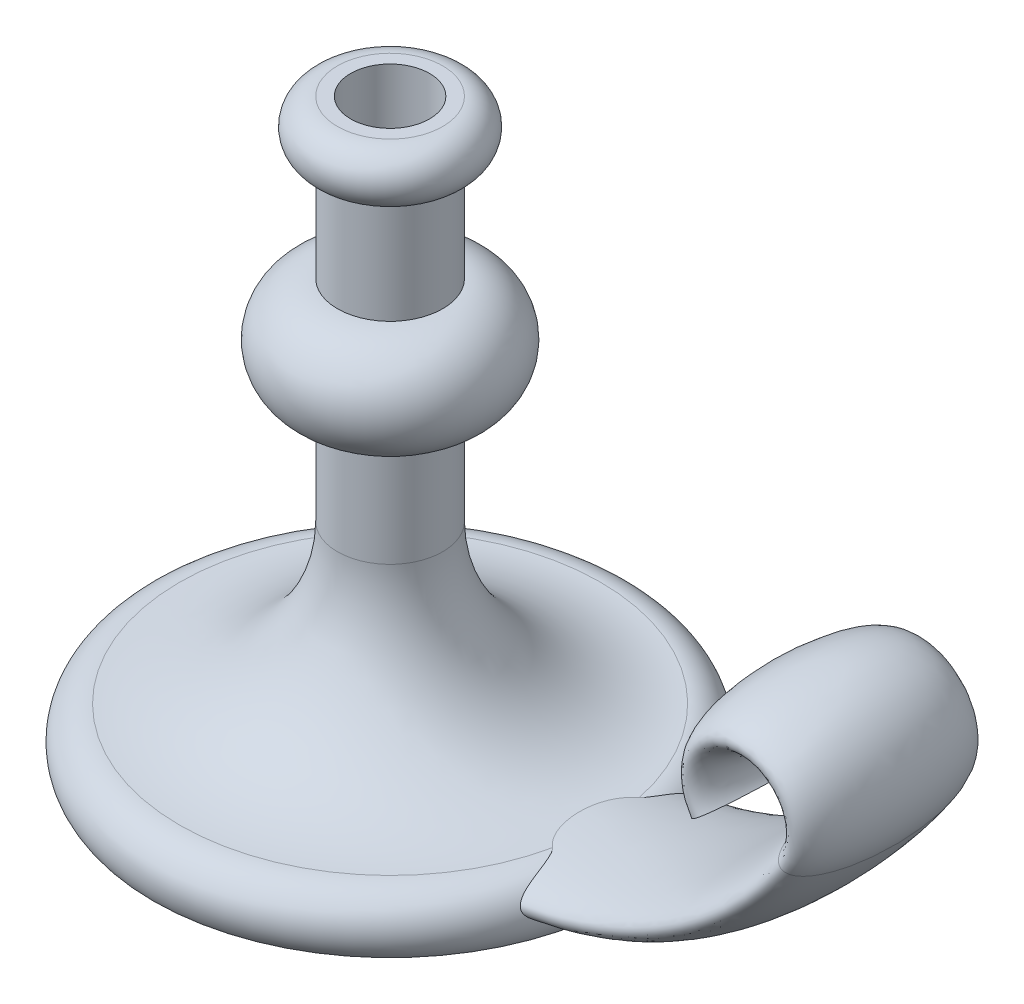
from build123d import *

# Parameters (mm, degrees)
SKETCH3_RX         = 35
SKETCH3_RY         = 10
SKETCH7_R          = 15
CUT_EXTRUDE1_DEPTH = 25


with BuildPart() as part:
    # Sketch1 → Revolve1 (revolve)
    with BuildSketch(Plane.XY):
        with BuildLine():
            Line((0, 127.495412844), (0, -92.504587156))
            Line((0, -92.504587156), (90, -92.504587156))
            ThreePointArc((90, -92.504587156), (91.180339887, -79.414417212), (80, -72.504587156))
            ThreePointArc((80, -72.504587156), (37.573593129, -54.930994027), (20, -12.504587156))
            Line((20, -12.504587156), (20, 27.495412844))
            ThreePointArc((20, 27.495412844), (40, 47.495412844), (20, 67.495412844))
            Line((20, 67.495412844), (20, 107.495412844))
            ThreePointArc((20, 107.495412844), (30, 117.495412844), (20, 127.495412844))
            Line((20, 127.495412844), (0, 127.495412844))
        make_face()
    revolve(axis=Axis((0, 127.495412844, 0), (0, -1, 0)))

    # Sweep1: sweep along a path in Sketch2
    with BuildLine(Plane.XY) as sweep1_path:
        Line((0, -82.504587156), (60, -82.504587156))
        ThreePointArc((60, -82.504587156), (129.821200219, -65.263767629), (183.592070943, -17.504587156))
        ThreePointArc((183.592070943, -17.504587156), (167.113128151, 13.828746177), (150.634185358, -17.504587156))
    # Sketch3 → Sweep1 (sweep)
    with BuildSketch(Plane(origin=(0, 0, 0), x_dir=(0, 0, -1), z_dir=(1, 0, 0))):
        with Locations((0, -82.504587156)):
            Ellipse(SKETCH3_RX, SKETCH3_RY)
    sweep(path=sweep1_path.line)

    # Sketch7 → Cut-Extrude1 (cut)
    with BuildSketch(Plane(origin=(0, 127.495412844, 0), x_dir=(1, 0, 0), z_dir=(0, 1, 0))):
        Circle(SKETCH7_R)
    extrude(amount=-CUT_EXTRUDE1_DEPTH, mode=Mode.SUBTRACT)


solid = part.part
